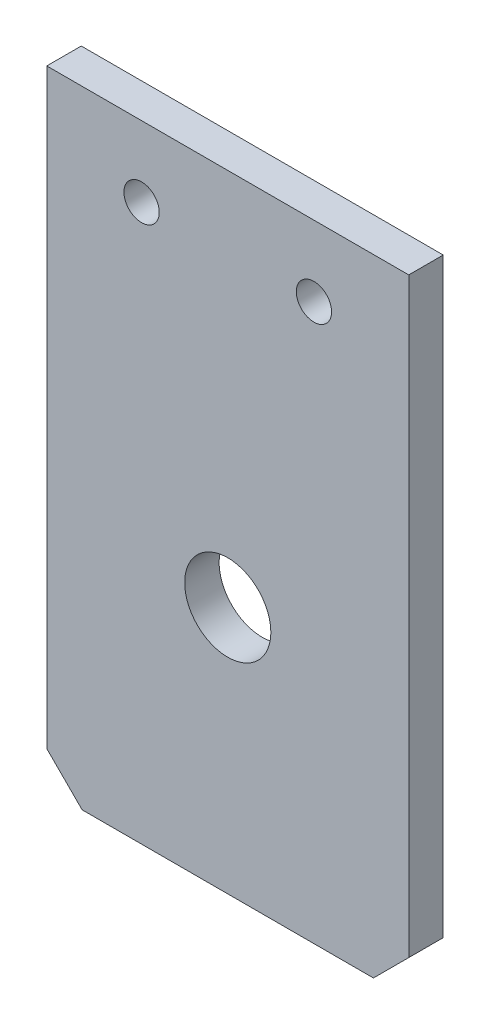
from build123d import *

# Parameters (mm, degrees)
CROQUIS1_W              = 42
CROQUIS1_H              = 65
CROQUIS1_R              = 2.05
SALIENTE_EXTRUIR1_DEPTH = 4
CROQUIS5_R              = 5
CORTAR_EXTRUIR2_DEPTH   = 5
CROQUIS6_W              = 42
CROQUIS6_H              = 7.7
SALIENTE_EXTRUIR2_DEPTH = 4
CHAFL_N1_SIZE           = 4.1


with BuildPart() as part:
    # Croquis1 → Saliente-Extruir1 (new body)
    with BuildSketch(Plane.XY):
        with Locations((21, 32.5)):
            Rectangle(CROQUIS1_W, CROQUIS1_H)
        with Locations((11, 56.8)):
            Circle(CROQUIS1_R, mode=Mode.SUBTRACT)
        with Locations((31, 56.8)):
            Circle(CROQUIS1_R, mode=Mode.SUBTRACT)
    extrude(amount=SALIENTE_EXTRUIR1_DEPTH)

    # Croquis5 → Cortar-Extruir2 (cut, through all)
    with BuildSketch(Plane.XY.offset(4)):
        with Locations((21, 21.08)):
            Circle(CROQUIS5_R)
    extrude(amount=-CORTAR_EXTRUIR2_DEPTH, mode=Mode.SUBTRACT)

    # Croquis6 → Saliente-Extruir2 (add, through all)
    with BuildSketch(Plane.XY.offset(4)):
        with Locations((21, -3.85)):
            Rectangle(CROQUIS6_W, CROQUIS6_H)
    extrude(amount=-SALIENTE_EXTRUIR2_DEPTH)

    # Chaflán1
    chafl_n1_edges = [part.edges().sort_by_distance(p)[0] for p in [
        (0, -7.7, 2),
        (42, -7.7, 2),
    ]]
    chamfer(chafl_n1_edges, length=CHAFL_N1_SIZE)


solid = part.part
